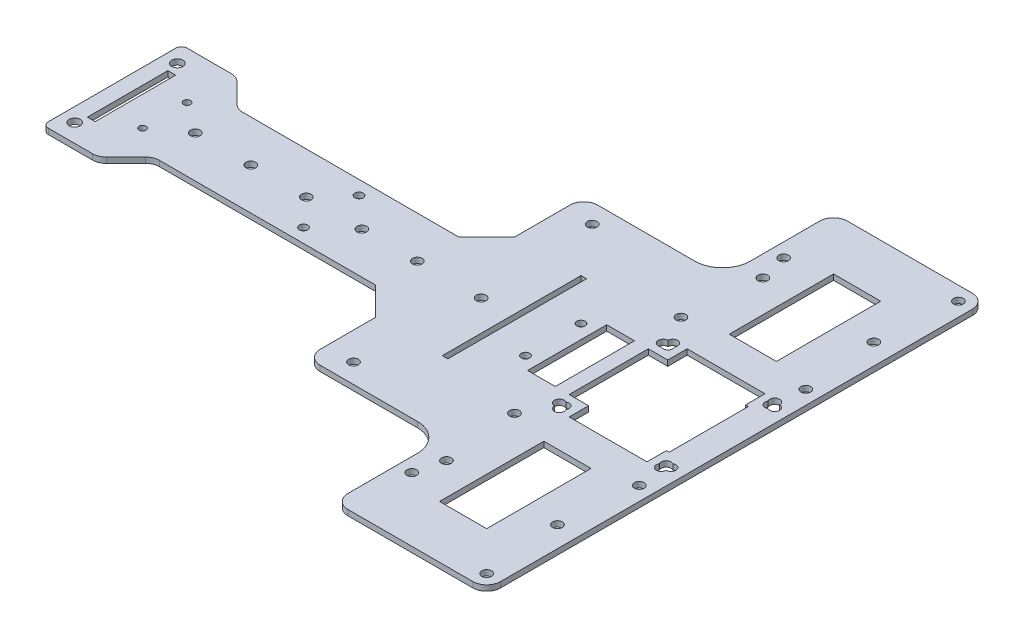
from build123d import *

# Parameters (mm, degrees)
SKETCH1_R           = 1.75
SKETCH1_R_2         = 2
SKETCH1_R_3         = 1.25
SKETCH1_W           = 2.8
SKETCH1_H           = 29
BOSS_EXTRUDE1_DEPTH = 2
SKETCH3_R           = 1.75
SKETCH3_W           = 17
SKETCH3_H           = 37.6
SKETCH3_W_2         = 2
SKETCH3_H_2         = 50
SKETCH3_W_3         = 50
SKETCH3_H_3         = 40
SKETCH3_W_4         = 10
SKETCH3_H_4         = 28.52743249
CUT_EXTRUDE1_DEPTH  = 10
FILLET1_R           = 2
FILLET2_R           = 5
FILLET3_R           = 10
CUT_EXTRUDE2_DEPTH  = 10
SKETCH5_R           = 1.75
SKETCH5_R_2         = 1.5
CUT_EXTRUDE3_DEPTH  = 10
FILLET4_R           = 5


with BuildPart() as part:
    # Sketch1 → Boss-Extrude1 (new body)
    with BuildSketch(Plane(origin=(0, 0, 0), x_dir=(1, 0, 0), z_dir=(0, 1, 0))):
        Polygon((20, 90), (125, 90), (125, -90), (20, -90), (20, -25), (-100, -25), (-100, 25), (20, 25), align=None)
        with Locations((120, -85)):
            Circle(SKETCH1_R, mode=Mode.SUBTRACT)
        with Locations((120, 85)):
            Circle(SKETCH1_R, mode=Mode.SUBTRACT)
        with Locations((75, -67)):
            Circle(SKETCH1_R, mode=Mode.SUBTRACT)
        with Locations((120, -30)):
            Circle(SKETCH1_R, mode=Mode.SUBTRACT)
        with Locations((75, -30)):
            Circle(SKETCH1_R, mode=Mode.SUBTRACT)
        with Locations((75, 67)):
            Circle(SKETCH1_R, mode=Mode.SUBTRACT)
        with Locations((-95, -18.5)):
            Circle(SKETCH1_R_2, mode=Mode.SUBTRACT)
        with Locations((-95, 18.5)):
            Circle(SKETCH1_R_2, mode=Mode.SUBTRACT)
        with Locations((-81, 8)):
            Circle(SKETCH1_R_3, mode=Mode.SUBTRACT)
        with Locations((-81, -8)):
            Circle(SKETCH1_R_3, mode=Mode.SUBTRACT)
        with Locations((120, 30)):
            Circle(SKETCH1_R, mode=Mode.SUBTRACT)
        with Locations((75, 30)):
            Circle(SKETCH1_R, mode=Mode.SUBTRACT)
        with Locations((30, -43)):
            Circle(SKETCH1_R, mode=Mode.SUBTRACT)
        with Locations((30, 43)):
            Circle(SKETCH1_R, mode=Mode.SUBTRACT)
        with Locations((-93, 0)):
            Rectangle(SKETCH1_W, SKETCH1_H, mode=Mode.SUBTRACT)
    extrude(amount=BOSS_EXTRUDE1_DEPTH)

    # Sketch3 → Cut-Extrude1 (cut)
    with BuildSketch(Plane(origin=(0, 2, 0), x_dir=(1, 0, 0), z_dir=(0, 1, 0))):
        with Locations((77.5, 57)):
            Circle(SKETCH3_R)
        with Locations((117.5, 57)):
            Circle(SKETCH3_R)
        with Locations((117.5, -57)):
            Circle(SKETCH3_R)
        with Locations((77.5, -57)):
            Circle(SKETCH3_R)
        with Locations((81.63, 18.69)):
            Circle(SKETCH3_R)
        with Locations((118.37, 18.69)):
            Circle(SKETCH3_R)
        with Locations((81.63, -18.69)):
            Circle(SKETCH3_R)
        with Locations((118.37, -18.69)):
            Circle(SKETCH3_R)
        with Locations((33, 0)):
            Circle(SKETCH3_R)
        with Locations((97.5, 52.2)):
            Rectangle(SKETCH3_W, SKETCH3_H)
        with Locations((97.5, -52.2)):
            Rectangle(SKETCH3_W, SKETCH3_H)
        Polygon((85.980499335, 14.263716245), (85.980499335, 21.263716245), (114.019500665, 21.263716245), (114.019500665, 14.263716245), (115.019500665, 14.263716245), (115.019500665, -14.263716245), (114.019500665, -14.263716245), (114.019500665, -21.263716245), (85.980499335, -21.263716245), (85.980499335, -14.263716245), (78.980499335, -14.263716245), (78.980499335, 14.263716245), align=None)
        with Locations((45, 0)):
            Rectangle(SKETCH3_W_2, SKETCH3_H_2)
        with Locations((45, -70)):
            Rectangle(SKETCH3_W_3, SKETCH3_H_3)
        with Locations((45, 70)):
            Rectangle(SKETCH3_W_3, SKETCH3_H_3)
        with Locations((68.980499335, 0)):
            Rectangle(SKETCH3_W_4, SKETCH3_H_4)
    extrude(amount=-CUT_EXTRUDE1_DEPTH, mode=Mode.SUBTRACT)

    # Fillet1
    fillet1_edges = [part.edges().sort_by_distance(p)[0] for p in [
        (-100, 1, 25),
        (-100, 1, -25),
    ]]
    fillet(fillet1_edges, radius=FILLET1_R)

    # Fillet2
    fillet2_edges = [part.edges().sort_by_distance(p)[0] for p in [
        (20, 1, -50),
        (125, 1, 90),
        (125, 1, -90),
        (20, 1, 50),
        (70, 1, -90),
        (70, 1, 90),
    ]]
    fillet(fillet2_edges, radius=FILLET2_R)

    # Fillet3
    fillet3_edges = [part.edges().sort_by_distance(p)[0] for p in [
        (70, 1, 50),
        (70, 1, -50),
    ]]
    fillet(fillet3_edges, radius=FILLET3_R)

    # Sketch4 → Cut-Extrude2 (cut)
    with BuildSketch(Plane(origin=(0, 2, 0), x_dir=(1, 0, 0), z_dir=(0, 1, 0))):
        with BuildLine():
            ThreePointArc((118.37, 18.69), (121.357436867, 17.452563133), (120.12, 20.44))
            ThreePointArc((120.12, 20.44), (117.132563133, 21.677436867), (118.37, 18.69))
        make_face()
        with BuildLine():
            ThreePointArc((120.12, -20.44), (121.357436867, -17.452563133), (118.37, -18.69))
            ThreePointArc((118.37, -18.69), (117.132563133, -21.677436867), (120.12, -20.44))
        make_face()
        with BuildLine():
            ThreePointArc((79.88, -20.44), (82.867436867, -21.677436867), (81.63, -18.69))
            ThreePointArc((81.63, -18.69), (78.642563133, -17.452563133), (79.88, -20.44))
        make_face()
        with BuildLine():
            ThreePointArc((79.88, 20.44), (78.642563133, 17.452563133), (81.63, 18.69))
            ThreePointArc((81.63, 18.69), (82.867436867, 21.677436867), (79.88, 20.44))
        make_face()
    extrude(amount=-CUT_EXTRUDE2_DEPTH, mode=Mode.SUBTRACT)

    # Sketch5 → Cut-Extrude3 (cut)
    with BuildSketch(Plane(origin=(0, 2, 0), x_dir=(1, 0, 0), z_dir=(0, 1, 0))):
        with Locations((-70, 0)):
            Circle(SKETCH5_R)
        with Locations((-50, 0)):
            Circle(SKETCH5_R)
        with Locations((-30, 0)):
            Circle(SKETCH5_R)
        with Locations((-10, 0)):
            Circle(SKETCH5_R)
        with Locations((10, 0)):
            Circle(SKETCH5_R)
        with Locations((58.980499335, 10)):
            Circle(SKETCH5_R_2)
        with Locations((58.980499335, -10)):
            Circle(SKETCH5_R_2)
        with Locations((-21.019500665, 10)):
            Circle(SKETCH5_R_2)
        with Locations((-21.019500665, -10)):
            Circle(SKETCH5_R_2)
        Polygon((20, 25), (-80, 25), (-70, 15), (10, 15), align=None)
        Polygon((-70, -15), (10, -15), (20, -25), (-80, -25), align=None)
    extrude(amount=-CUT_EXTRUDE3_DEPTH, mode=Mode.SUBTRACT)

    # Fillet4
    fillet4_edges = [part.edges().sort_by_distance(p)[0] for p in [
        (-80, 1, -25),
        (-70, 1, -15),
        (-70, 1, 15),
        (-80, 1, 25),
    ]]
    fillet(fillet4_edges, radius=FILLET4_R)


solid = part.part
